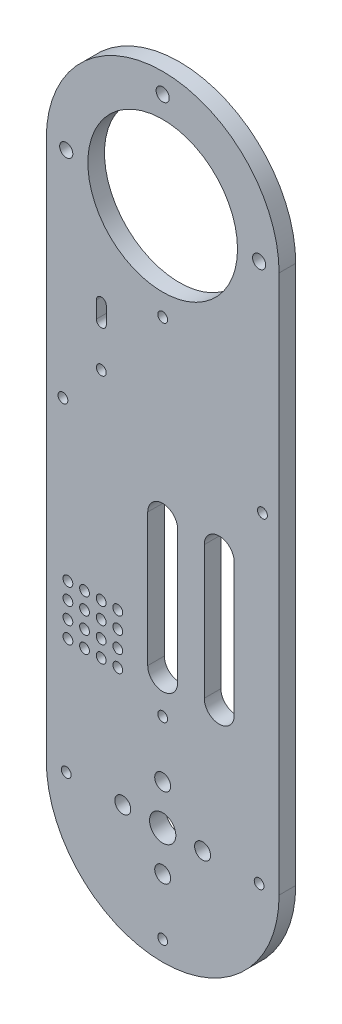
from build123d import *

# Parameters (mm, degrees)
SKETCH1_R           = 3.95
SKETCH1_R_2         = 1.475
SKETCH1_R_3         = 22.5
SKETCH1_R_4         = 2.4
SKETCH1_R_5         = 1.975
BOSS_EXTRUDE1_DEPTH = 5


with BuildPart() as part:
    # Sketch1 → Boss-Extrude1 (new body)
    with BuildSketch(Plane.XY):
        with BuildLine():
            Line((35, 0), (35, 162))
            ThreePointArc((35, 162), (0, 197), (-35, 162))
            Line((-35, 162), (-35, 0))
            ThreePointArc((-35, 0), (0, -35), (35, 0))
        make_face()
        Circle(SKETCH1_R, mode=Mode.SUBTRACT)
        with Locations((0, 29)):
            Circle(SKETCH1_R_2, mode=Mode.SUBTRACT)
        with Locations((0, 162)):
            Circle(SKETCH1_R_3, mode=Mode.SUBTRACT)
        with Locations((0, 133)):
            Circle(SKETCH1_R_2, mode=Mode.SUBTRACT)
        with Locations((-30, 97)):
            Circle(SKETCH1_R_2, mode=Mode.SUBTRACT)
        with Locations((30, 97)):
            Circle(SKETCH1_R_2, mode=Mode.SUBTRACT)
        with Locations((29, 0)):
            Circle(SKETCH1_R_2, mode=Mode.SUBTRACT)
        with Locations((0, -29)):
            Circle(SKETCH1_R_2, mode=Mode.SUBTRACT)
        with Locations((-29, 0)):
            Circle(SKETCH1_R_2, mode=Mode.SUBTRACT)
        with Locations((0, 12)):
            Circle(SKETCH1_R_4, mode=Mode.SUBTRACT)
        with Locations((12, 0)):
            Circle(SKETCH1_R_4, mode=Mode.SUBTRACT)
        with Locations((0, -12)):
            Circle(SKETCH1_R_4, mode=Mode.SUBTRACT)
        with Locations((-12, 0)):
            Circle(SKETCH1_R_4, mode=Mode.SUBTRACT)
        with Locations((0, 191)):
            Circle(SKETCH1_R_5, mode=Mode.SUBTRACT)
        with Locations((29, 162)):
            Circle(SKETCH1_R_5, mode=Mode.SUBTRACT)
        with Locations((-29, 162)):
            Circle(SKETCH1_R_5, mode=Mode.SUBTRACT)
        with Locations((-18.45, 110)):
            Circle(SKETCH1_R_2, mode=Mode.SUBTRACT)
        with Locations((-28.5, 35)):
            Circle(SKETCH1_R_2, mode=Mode.SUBTRACT)
        with Locations((-23.5, 35)):
            Circle(SKETCH1_R_2, mode=Mode.SUBTRACT)
        with Locations((-18.5, 35)):
            Circle(SKETCH1_R_2, mode=Mode.SUBTRACT)
        with Locations((-13.5, 35)):
            Circle(SKETCH1_R_2, mode=Mode.SUBTRACT)
        with Locations((-28.5, 40)):
            Circle(SKETCH1_R_2, mode=Mode.SUBTRACT)
        with Locations((-23.5, 40)):
            Circle(SKETCH1_R_2, mode=Mode.SUBTRACT)
        with Locations((-18.5, 40)):
            Circle(SKETCH1_R_2, mode=Mode.SUBTRACT)
        with Locations((-13.5, 40)):
            Circle(SKETCH1_R_2, mode=Mode.SUBTRACT)
        with Locations((-28.5, 45)):
            Circle(SKETCH1_R_2, mode=Mode.SUBTRACT)
        with Locations((-23.5, 45)):
            Circle(SKETCH1_R_2, mode=Mode.SUBTRACT)
        with Locations((-18.5, 45)):
            Circle(SKETCH1_R_2, mode=Mode.SUBTRACT)
        with Locations((-13.5, 45)):
            Circle(SKETCH1_R_2, mode=Mode.SUBTRACT)
        with Locations((-28.5, 50)):
            Circle(SKETCH1_R_2, mode=Mode.SUBTRACT)
        with Locations((-23.5, 50)):
            Circle(SKETCH1_R_2, mode=Mode.SUBTRACT)
        with Locations((-18.5, 50)):
            Circle(SKETCH1_R_2, mode=Mode.SUBTRACT)
        with Locations((-13.5, 50)):
            Circle(SKETCH1_R_2, mode=Mode.SUBTRACT)
        with BuildLine():
            Line((4.5, 80), (4.5, 40))
            ThreePointArc((4.5, 40), (0, 35.5), (-4.5, 40))
            Line((-4.5, 40), (-4.5, 80))
            ThreePointArc((-4.5, 80), (0, 84.5), (4.5, 80))
        make_face(mode=Mode.SUBTRACT)
        with BuildLine():
            Line((21.5, 80), (21.5, 40))
            ThreePointArc((21.5, 40), (17, 35.5), (12.5, 40))
            Line((12.5, 40), (12.5, 80))
            ThreePointArc((12.5, 80), (17, 84.5), (21.5, 80))
        make_face(mode=Mode.SUBTRACT)
        with BuildLine():
            Line((-16.95, 127.5), (-16.95, 122.5))
            ThreePointArc((-16.95, 122.5), (-18.45, 121), (-19.95, 122.5))
            Line((-19.95, 122.5), (-19.95, 127.5))
            ThreePointArc((-19.95, 127.5), (-18.45, 129), (-16.95, 127.5))
        make_face(mode=Mode.SUBTRACT)
    extrude(amount=BOSS_EXTRUDE1_DEPTH)


solid = part.part
